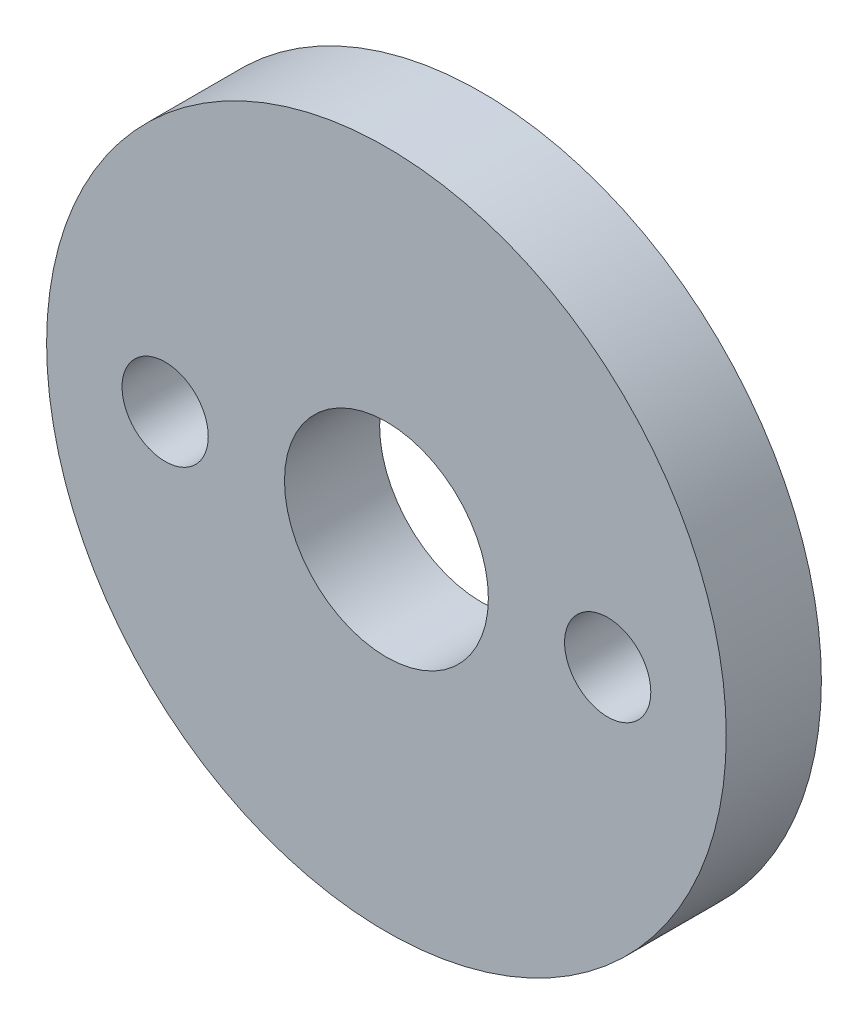
from build123d import *

# Parameters (mm, degrees)
SKETCH1_R           = 11.43
SKETCH1_R_2         = 3.429
BOSS_EXTRUDE1_DEPTH = 3.2004
SKETCH2_R           = 1.45
CUT_EXTRUDE1_DEPTH  = 3.2004


with BuildPart() as part:
    # Sketch1 → Boss-Extrude1 (new body)
    with BuildSketch(Plane.XY):
        Circle(SKETCH1_R)
        Circle(SKETCH1_R_2, mode=Mode.SUBTRACT)
    extrude(amount=BOSS_EXTRUDE1_DEPTH)

    # Sketch2 → Cut-Extrude1 (cut)
    with BuildSketch(Plane.XY.offset(3.2004)):
        with Locations((-7.442200054, 0)):
            Circle(SKETCH2_R)
        with Locations((7.442200054, 0)):
            Circle(SKETCH2_R)
    extrude(amount=-CUT_EXTRUDE1_DEPTH, mode=Mode.SUBTRACT)


solid = part.part
